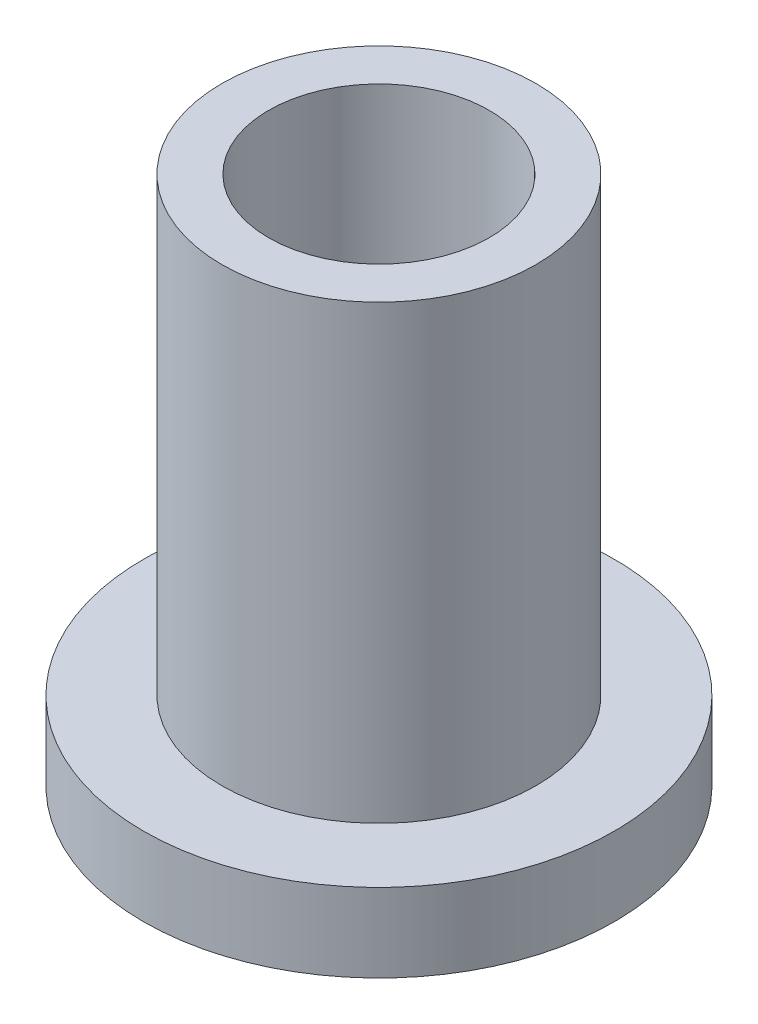
from build123d import *

# Parameters (mm, degrees)
SKETCH1_R           = 5.08
SKETCH1_R_2         = 3.571875
BOSS_EXTRUDE1_DEPTH = 17.145
SKETCH1_3_R         = 7.62
SKETCH1_3_R_2       = 5.08
BOSS_EXTRUDE2_DEPTH = 2.54


with BuildPart() as part:
    # Sketch1 → Boss-Extrude1 (new body)
    with BuildSketch(Plane(origin=(0, 0, 0), x_dir=(1, 0, 0), z_dir=(0, 1, 0))):
        Circle(SKETCH1_R)
        Circle(SKETCH1_R_2, mode=Mode.SUBTRACT)
    extrude(amount=BOSS_EXTRUDE1_DEPTH)

    # Sketch1_3 → Boss-Extrude2 (add)
    with BuildSketch(Plane(origin=(0, 0, 0), x_dir=(1, 0, 0), z_dir=(0, 1, 0))):
        Circle(SKETCH1_3_R)
        Circle(SKETCH1_3_R_2, mode=Mode.SUBTRACT)
    extrude(amount=BOSS_EXTRUDE2_DEPTH)


solid = part.part
